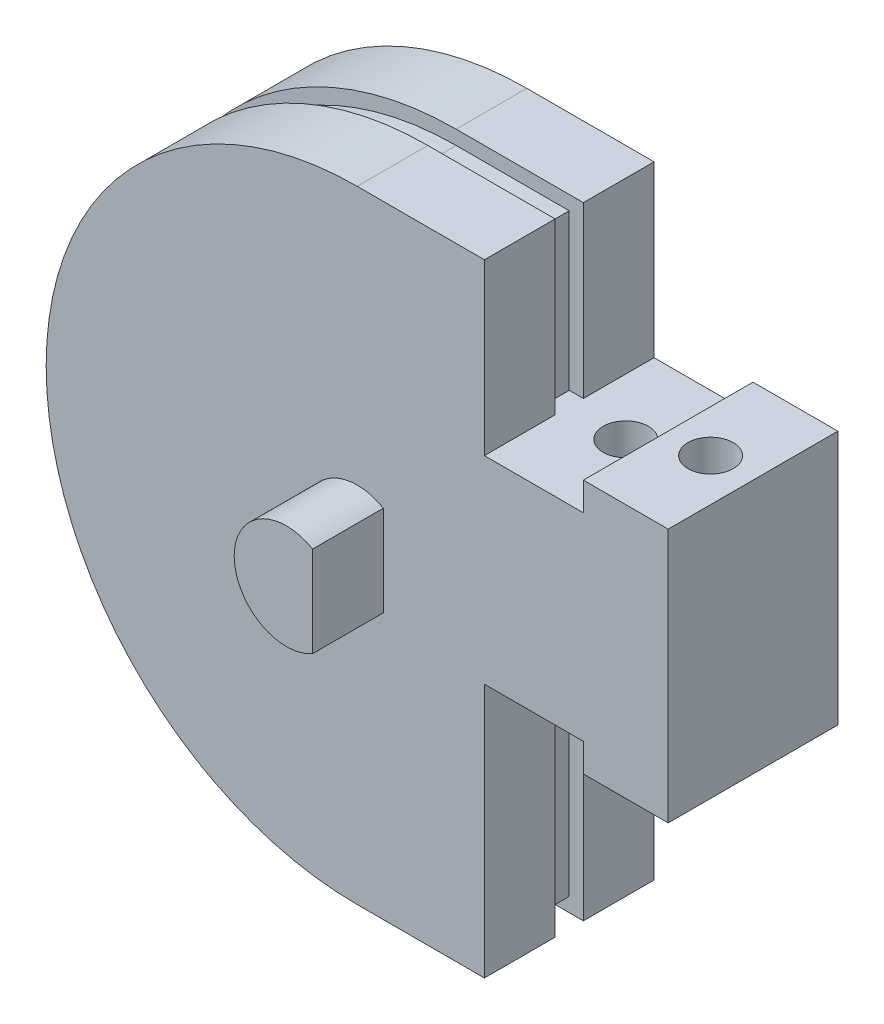
from build123d import *

# Parameters (mm, degrees)
BOSS_EXTRUDE1_DEPTH = 6
CUT_EXTRUDE1_START  = 10
SKETCH2_R           = 0.8
CUT_EXTRUDE1_DEPTH  = 22
CUT_EXTRUDE2_START  = 3
CUT_EXTRUDE2_DEPTH  = 0.5
BOSS_EXTRUDE2_START = 6
BOSS_EXTRUDE2_DEPTH = 2.5
SKETCH5_R           = 2.75
CUT_EXTRUDE3_DEPTH  = 3.5


with BuildPart() as part:
    # Sketch1 → Boss-Extrude1 (new body)
    with BuildSketch(Plane.XY):
        with BuildLine():
            Line((11, 6), (11, -3))
            Line((11, -3), (8, -3))
            Line((8, -3), (8, -2))
            Line((8, -2), (4.5, -2))
            Line((4.5, -2), (4.5, -11))
            Line((4.5, -11), (0, -11))
            ThreePointArc((0, -11), (-11, 0), (0, 11))
            Line((0, 11), (4.5, 11))
            Line((4.5, 11), (4.5, 5))
            Line((4.5, 5), (8, 5))
            Line((8, 5), (8, 6))
            Line((8, 6), (11, 6))
        make_face()
    extrude(amount=BOSS_EXTRUDE1_DEPTH)

    # Sketch2 → Cut-Extrude1 (cut, through all)
    with BuildSketch(Plane(origin=(0, 0, 0), x_dir=(1, 0, 0), z_dir=(0, 1, 0)).offset(CUT_EXTRUDE1_START)):
        with Locations((6.5, -3)):
            Circle(SKETCH2_R)
        with Locations((9.5, -3)):
            Circle(SKETCH2_R)
    extrude(amount=-CUT_EXTRUDE1_DEPTH, mode=Mode.SUBTRACT)

    # Sketch3 → Cut-Extrude2 (cut, symmetric)
    with BuildSketch(Plane.XY.offset(CUT_EXTRUDE2_START)):
        with BuildLine():
            Line((0, 11), (4.5, 11))
            Line((4.5, 11), (4.5, 5))
            Line((4.5, 5), (4, 5))
            Line((4, 5), (4, 10.5))
            Line((4, 10.5), (0, 10.5))
            ThreePointArc((0, 10.5), (-10.5, 0), (0, -10.5))
            Line((0, -10.5), (4, -10.5))
            Line((4, -10.5), (4, -2))
            Line((4, -2), (4.5, -2))
            Line((4.5, -2), (4.5, -11))
            Line((4.5, -11), (0, -11))
            ThreePointArc((0, -11), (-11, 0), (0, 11))
        make_face()
    extrude(amount=CUT_EXTRUDE2_DEPTH, both=True, mode=Mode.SUBTRACT)

    # Sketch4 → Boss-Extrude2 (add)
    with BuildSketch(Plane.XY.offset(BOSS_EXTRUDE2_START)):
        with BuildLine():
            Line((0.925, 1.602146997), (0.925, -1.602146997))
            ThreePointArc((0.925, -1.602146997), (-1.85, 0), (0.925, 1.602146997))
        make_face()
    extrude(amount=BOSS_EXTRUDE2_DEPTH)

    # Sketch5 → Cut-Extrude3 (cut)
    with BuildSketch(Plane.XY):
        Circle(SKETCH5_R)
    extrude(amount=CUT_EXTRUDE3_DEPTH, mode=Mode.SUBTRACT)


solid = part.part
